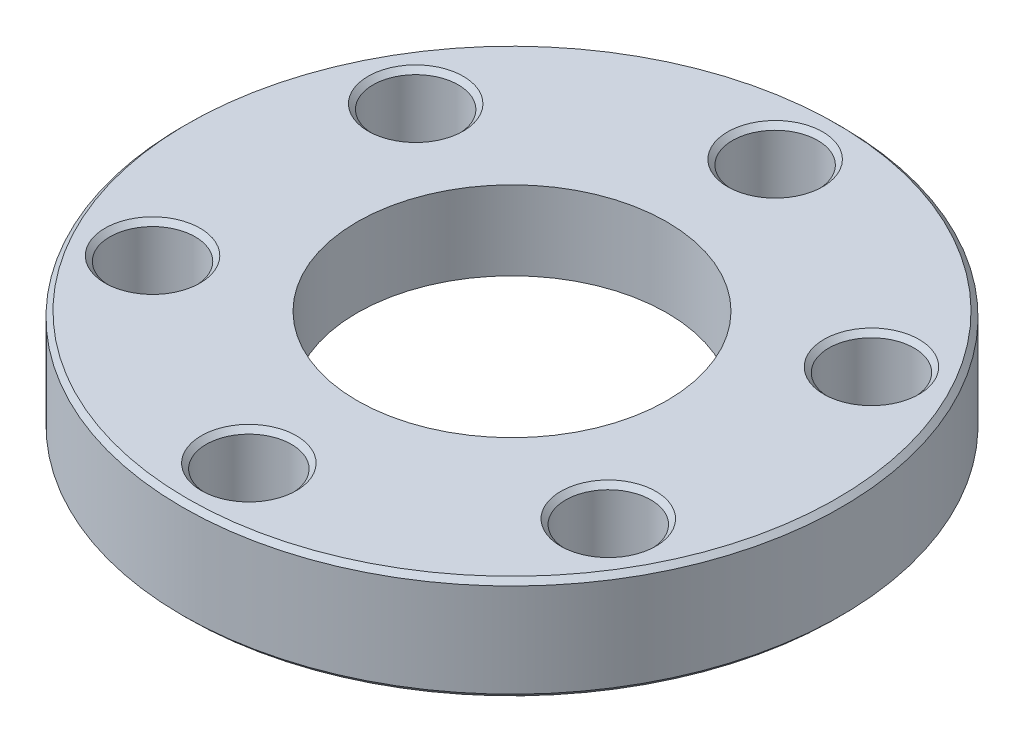
from build123d import *

# Parameters (mm, degrees)
SKETCH1_R                    = 16.891
SKETCH1_R_2                  = 7.9375
BOSS_EXTRUDE1_DEPTH          = 12.7
SKETCH2_R                    = 20.6375
CUT_EXTRUDE1_DEPTH           = 7.3914
CHAMFER1_SIZE                = 0.254
SKETCH4_R                    = 2.1844
CUT_EXTRUDE2_DEPTH           = 6.3086
CHAMFER2_SIZE                = 0.254
CIRPATTERN1_COUNT            = 6
CHAMFER2_OF_CIRPATTERN1_SIZE = 0.254


with BuildPart() as part:
    # Sketch1 → Boss-Extrude1 (new body)
    with BuildSketch(Plane(origin=(0, 0, 0), x_dir=(1, 0, 0), z_dir=(0, 1, 0))):
        Circle(SKETCH1_R)
        Circle(SKETCH1_R_2, mode=Mode.SUBTRACT)
    extrude(amount=BOSS_EXTRUDE1_DEPTH)

    # Sketch2 → Cut-Extrude1 (cut)
    with BuildSketch(Plane(origin=(0, 12.7, 0), x_dir=(1, 0, 0), z_dir=(0, 1, 0))):
        Circle(SKETCH2_R)
    extrude(amount=-CUT_EXTRUDE1_DEPTH, mode=Mode.SUBTRACT)

    # Chamfer1
    chamfer1_edges = [part.edges().sort_by_distance(p)[0] for p in [
        (-16.891, 5.3086, 0),
        (-16.891, 0, 0),
    ]]
    chamfer(chamfer1_edges, length=CHAMFER1_SIZE)

    # Sketch3 → Cut-Revolve1 (revolve, cut)
    with BuildSketch(Plane.XY):
        Polygon((-10.7188, 0), (-10.7188, 1.2446), (-9.144, 0.6604), (-9.144, 1.27), (0, 1.27), (0, 0), align=None)
    revolve(axis=Axis((0, 12.7, 0), (0, -1, 0)), mode=Mode.SUBTRACT)

    # Sketch4 → Cut-Extrude2 (cut, through all)
    with BuildSketch(Plane(origin=(0, 5.3086, 0), x_dir=(1, 0, 0), z_dir=(0, 1, 0))):
        with Locations((0, 13.4874)):
            Circle(SKETCH4_R)
    cut_extrude2 = extrude(amount=-CUT_EXTRUDE2_DEPTH, mode=Mode.SUBTRACT)

    # Chamfer2
    chamfer2_edges = [part.edges().sort_by_distance(p)[0] for p in [
        (-2.1844, 0, -13.4874),
        (-2.1844, 5.3086, -13.4874),
    ]]
    chamfer(chamfer2_edges, length=CHAMFER2_SIZE)

    # CirPattern1: Cut-Extrude2 ×6 about axis
    cirpattern1_axis = Axis((0, 0, 0), (0, 1, 0))
    for i in range(1, CIRPATTERN1_COUNT):
        add(cut_extrude2.rotate(cirpattern1_axis, i * 360 / CIRPATTERN1_COUNT), mode=Mode.SUBTRACT)

    # Chamfer2 of CirPattern1
    chamfer2_of_cirpattern1_edges = [part.edges().sort_by_distance(p)[0] for p in [
        (-12.772631031, 0, -4.851954108),
        (-12.772631031, 5.3086, -4.851954108),
        (-10.588231031, 0, 8.635445892),
        (-10.588231031, 5.3086, 8.635445892),
        (2.1844, 0, 13.4874),
        (2.1844, 5.3086, 13.4874),
        (12.772631031, 0, 4.851954108),
        (12.772631031, 5.3086, 4.851954108),
        (10.588231031, 0, -8.635445892),
        (10.588231031, 5.3086, -8.635445892),
    ]]
    chamfer(chamfer2_of_cirpattern1_edges, length=CHAMFER2_OF_CIRPATTERN1_SIZE)


solid = part.part
